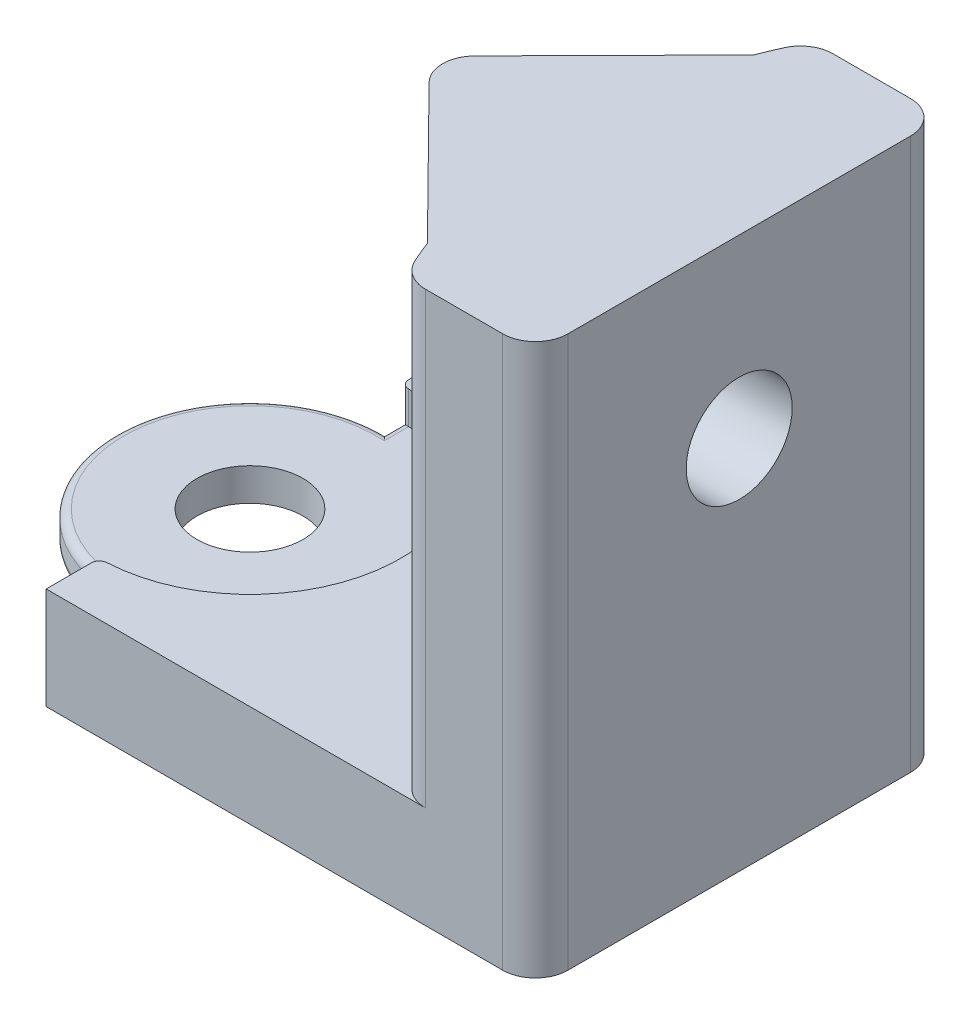
from build123d import *

# Parameters (mm, degrees)
BOSS_EXTRUDE1_DEPTH     = 2.25
BOSS_EXTRUDE2_START     = 2.25
SKETCH1_4_R             = 3.25
BOSS_EXTRUDE2_DEPTH     = 2
BOSS_EXTRUDE3_START     = 4.25
BOSS_EXTRUDE3_DEPTH     = 2
BOSS_EXTRUDE6_DEPTH     = 33.8
BOSS_EXTRUDE7_DEPTH     = 3.8
FILLET1_R               = 2
FILLET2_R               = 2
FILLET3_R               = 0.5
CUT_EXTRUDE1_REACH      = 54.552
CUT_EXTRUDE1_END_RADIUS = 27.541666667
SKETCH6_R               = 3.25


with BuildPart() as part:
    # Sketch1 → Boss-Extrude1 (new body)
    with BuildSketch(Plane(origin=(0, 0, 0), x_dir=(1, 0, 0), z_dir=(0, 1, 0))):
        with BuildLine():
            Line((30, -12.5), (30, 12.5))
            Line((30, 12.5), (0, 12.5))
            Line((0, 12.5), (0, 9.25))
            ThreePointArc((0, 9.25), (9.25, 0), (0, -9.25))
            Line((0, -9.25), (0, -12.5))
            Line((0, -12.5), (30, -12.5))
        make_face()
    extrude(amount=BOSS_EXTRUDE1_DEPTH)

    # Sketch1_4 → Boss-Extrude2 (add)
    with BuildSketch(Plane(origin=(0, 0, 0), x_dir=(1, 0, 0), z_dir=(0, 1, 0)).offset(BOSS_EXTRUDE2_START)):
        with BuildLine():
            Line((30, -12.5), (30, 12.5))
            Line((30, 12.5), (0, 12.5))
            Line((0, 12.5), (0, 8.25))
            ThreePointArc((0, 8.25), (-8.25, 0), (0, -8.25))
            Line((0, -8.25), (0, -12.5))
            Line((0, -12.5), (30, -12.5))
        make_face()
        with Locations(Location((0, 0, 0), (0, 0, 270))):
            Circle(SKETCH1_4_R, mode=Mode.SUBTRACT)
    extrude(amount=BOSS_EXTRUDE2_DEPTH)

    # Sketch1_6 → Boss-Extrude3 (add)
    with BuildSketch(Plane(origin=(0, 0, 0), x_dir=(1, 0, 0), z_dir=(0, 1, 0)).offset(BOSS_EXTRUDE3_START)):
        with BuildLine():
            Line((0, -12.5), (22, -12.5))
            ThreePointArc((22, -12.5), (19, 0), (22, 12.5))
            Line((22, 12.5), (0, 12.5))
            Line((0, 12.5), (0, 9.25))
            ThreePointArc((0, 9.25), (9.25, 0), (0, -9.25))
            Line((0, -9.25), (0, -12.5))
        make_face()
        with BuildLine():
            Line((22, -12.5), (30, -12.5))
            Line((30, -12.5), (30, 12.5))
            Line((30, 12.5), (22, 12.5))
            ThreePointArc((22, 12.5), (19, 0), (22, -12.5))
        make_face()
    extrude(amount=BOSS_EXTRUDE3_DEPTH)

    # Sketch1_8 → Boss-Extrude6 (add)
    with BuildSketch(Plane(origin=(0, 0, 0), x_dir=(1, 0, 0), z_dir=(0, 1, 0))):
        with BuildLine():
            Line((22, -12.5), (30, -12.5))
            Line((30, -12.5), (30, 12.5))
            Line((30, 12.5), (22, 12.5))
            ThreePointArc((22, 12.5), (19, 0), (22, -12.5))
        make_face()
    extrude(amount=BOSS_EXTRUDE6_DEPTH)

    # Sketch3 → Boss-Extrude7 (add)
    with BuildSketch(Plane(origin=(0, 33.8, 0), x_dir=(1, 0, 0), z_dir=(0, 1, 0))):
        with BuildLine():
            Line((11, 0), (19, 0))
            ThreePointArc((19, 0), (19.473969858, 5.087552676), (20.879566153, 10))
            Line((20.879566153, 10), (11, 0))
        make_face()
        with BuildLine():
            ThreePointArc((20.879566153, -10), (19.473969858, -5.087552676), (19, 0))
            Line((19, 0), (11, 0))
            Line((11, 0), (20.879566153, -10))
        make_face()
        with BuildLine():
            ThreePointArc((20.879566153, 10), (19.473969858, 5.087552676), (19, 0))
            ThreePointArc((19, 0), (19.473969858, -5.087552676), (20.879566153, -10))
            ThreePointArc((20.879566153, -10), (21.408679185, -11.263939941), (22, -12.5))
            Line((22, -12.5), (30, -12.5))
            Line((30, -12.5), (30, 12.5))
            Line((30, 12.5), (22, 12.5))
            ThreePointArc((22, 12.5), (21.408679185, 11.263939941), (20.879566153, 10))
        make_face()
    extrude(amount=-BOSS_EXTRUDE7_DEPTH)

    # Fillet1
    fillet1_edges = [part.edges().sort_by_distance(p)[0] for p in [
        (11, 31.9, 0),
    ]]
    fillet(fillet1_edges, radius=FILLET1_R)

    # Fillet2
    fillet2_edges = [part.edges().sort_by_distance(p)[0] for p in [
        (30, 16.9, -12.5),
        (30, 16.9, 12.5),
        (22, 20.025, -12.5),
        (22, 20.025, 12.5),
    ]]
    fillet(fillet2_edges, radius=FILLET2_R)

    # Fillet3
    fillet3_edges = [part.edges().sort_by_distance(p)[0] for p in [
        (0, 1.125, 9.25),
        (0, 1.125, -9.25),
        (0, 2.25, -8.75),
        (0, 2.25, 8.75),
        (-8.25, 4.25, 0),
        (0, 4.25, 8.75),
        (-8.25, 2.25, 0),
        (0, 4.25, -8.75),
        (0, 5.25, -9.25),
        (0, 5.25, 9.25),
    ]]
    fillet(fillet3_edges, radius=FILLET3_R)

    # Cut-Extrude1: up to this cylinder (the profile starts inside it)
    cut_extrude1_end = Plane(origin=(46.541666667, 23, 0), z_dir=(0, -1, 0)) * Cylinder(CUT_EXTRUDE1_END_RADIUS, 165.187333333, mode=Mode.PRIVATE)
    # Sketch6 → Cut-Extrude1 (cut, up to the surface)
    with BuildSketch(Plane(origin=(30, 0, 0), x_dir=(0, 0, -1), z_dir=(1, 0, 0)), mode=Mode.PRIVATE) as cut_extrude1_sk1:
        with Locations((0, 23)):
            Circle(SKETCH6_R)
    cut_extrude1_tool1 = extrude(cut_extrude1_sk1.sketch, amount=-CUT_EXTRUDE1_REACH, mode=Mode.PRIVATE) & cut_extrude1_end
    add(cut_extrude1_tool1.solids().sort_by_distance((30, 23, 0))[0], mode=Mode.SUBTRACT)


solid = part.part
